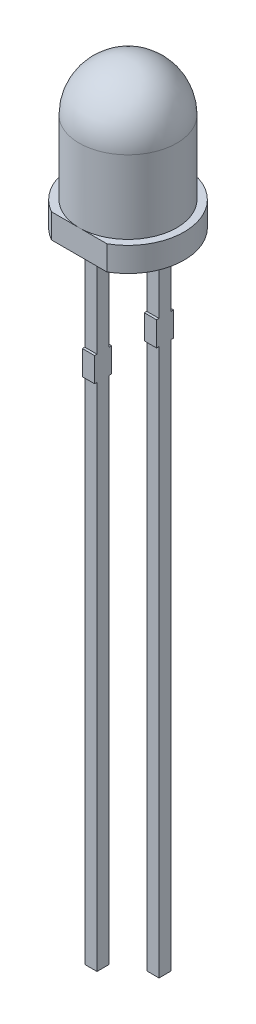
from build123d import *

# Parameters (mm, degrees)
EXTRUDE1_DEPTH     = 1
SKETCH3_W          = 0.5
SKETCH3_H          = 0.5
EXTRUDE2_DEPTH     = 25.5
SKETCH3_3_W        = 0.5
SKETCH3_3_H        = 0.5
EXTRUDE3_DEPTH     = 27
SKETCH4_W          = 0.7
SKETCH4_H          = 1
EXTRUDE4_DEPTH     = 0.5
SKETCH5_W          = 0.026582278
SKETCH5_H          = 0.025316456
CUT_EXTRUDE1_DEPTH = 0.01


with BuildPart() as part:
    # Sketch1 → Revolve1 (revolve)
    with BuildSketch(Plane.XY):
        with BuildLine():
            ThreePointArc((0, 5), (1.414213562, 4.414213562), (2, 3))
            Line((2, 3), (2, 0))
            Line((2, 0), (0, 0))
            Line((0, 0), (0, 5))
        make_face()
    revolve(axis=Axis((0, 0, 0), (0, 1, 0)))

    # Sketch2 → Extrude1 (add)
    with BuildSketch(Plane.XZ.offset(1)):
        with BuildLine():
            ThreePointArc((-1.135781669, 2), (0, -2.3), (1.135781669, 2))
            Line((1.135781669, 2), (-1.135781669, 2))
        make_face()
    extrude(amount=-EXTRUDE1_DEPTH)

    # Sketch3 → Extrude2 (add)
    with BuildSketch(Plane.XZ.offset(1)):
        with Locations((0, 1.27)):
            Rectangle(SKETCH3_W, SKETCH3_H)
    extrude(amount=EXTRUDE2_DEPTH)

    # Sketch3_3 → Extrude3 (add)
    with BuildSketch(Plane.XZ.offset(1)):
        with Locations((0, -1.27)):
            Rectangle(SKETCH3_3_W, SKETCH3_3_H)
    extrude(amount=EXTRUDE3_DEPTH)

    # Sketch4 → Extrude4 (add)
    with BuildSketch(Plane.ZY.offset(0.25)):
        with Locations((-1.27, -5.1)):
            Rectangle(SKETCH4_W, SKETCH4_H)
        with Locations((1.27, -5.1)):
            Rectangle(SKETCH4_W, SKETCH4_H)
    extrude(amount=-EXTRUDE4_DEPTH)

    # Sketch5 → Cut-Extrude1 (cut)
    with BuildSketch(Plane.XZ.offset(1)):
        Polygon((-0.175316456, 0.572151899), (-0.25, 0.595609177), (-0.25, 0.620352057), (-0.199663766, 0.636768196), (-0.25, 0.652294304), (-0.25, 0.678026108), (-0.175316456, 0.701265823), (-0.175316456, 0.676087816), (-0.226799842, 0.663093354), (-0.175316456, 0.646677215), (-0.175316456, 0.625178006), (-0.226799842, 0.608860759), (-0.175316456, 0.596044304), align=None)
        Polygon((-0.175316456, 0.437974684), (-0.25, 0.461431962), (-0.25, 0.486174842), (-0.199663766, 0.502590981), (-0.25, 0.518117089), (-0.25, 0.543848892), (-0.175316456, 0.567088608), (-0.175316456, 0.541910601), (-0.226799842, 0.528916139), (-0.175316456, 0.5125), (-0.175316456, 0.491000791), (-0.226799842, 0.474683544), (-0.175316456, 0.461867089), align=None)
        Polygon((-0.175316456, 0.303797468), (-0.25, 0.327254747), (-0.25, 0.351997627), (-0.199663766, 0.368413766), (-0.25, 0.383939873), (-0.25, 0.409671677), (-0.175316456, 0.432911392), (-0.175316456, 0.407733386), (-0.226799842, 0.394738924), (-0.175316456, 0.378322785), (-0.175316456, 0.356823576), (-0.226799842, 0.340506329), (-0.175316456, 0.327689873), align=None)
        with Locations((-0.236708861, 0.275949367)):
            Rectangle(SKETCH5_W, SKETCH5_H)
        with BuildLine():
            add(Edge.make_bspline(
                [(-0.218829114, 0.159493671), (-0.220051248, 0.159530169), (-0.22245111, 0.15960184), (-0.225958798, 0.160211426), (-0.229283102, 0.161205393), (-0.232447248, 0.162577732), (-0.235416736, 0.164371189), (-0.238219628, 0.16655446), (-0.240824172, 0.169143343), (-0.243260547, 0.172090146), (-0.245442658, 0.175387089), (-0.247348691, 0.178984804), (-0.248943362, 0.18286483), (-0.250282428, 0.187013042), (-0.251270861, 0.191459588), (-0.251994849, 0.196177087), (-0.252468166, 0.201170514), (-0.252510134, 0.204594091), (-0.252531646, 0.206348892)],
                knots=[0, 0, 0, 0, 0.907312236, 1.78165839, 2.635367075, 3.479697475, 4.336364812, 5.205276731, 6.11257575, 7.058770404, 8.040786331, 9.044147278, 10.078219212, 11.153049307, 12.278104542, 13.457648573, 14.696882856, 16, 16, 16, 16], degree=3))
            add(Edge.make_bspline(
                [(-0.252531646, 0.206348892), (-0.252507574, 0.208367148), (-0.252460949, 0.21227633), (-0.25203235, 0.217939855), (-0.251386211, 0.223207892), (-0.250419669, 0.228103607), (-0.249218904, 0.232708206), (-0.247927612, 0.237141474), (-0.246463197, 0.241422786), (-0.245363039, 0.244195876), (-0.244818038, 0.24556962)],
                knots=[0, 0, 0, 0, 1.203215828, 2.33052265, 3.384689099, 4.366106119, 5.303329643, 6.221311756, 7.118865988, 8, 8, 8, 8], degree=3))
            Line((-0.244818038, 0.24556962), (-0.220886076, 0.24556962))
            Line((-0.220886076, 0.24556962), (-0.220886076, 0.242721519))
            add(Edge.make_bspline(
                [(-0.220886076, 0.242721519), (-0.221967531, 0.241356205), (-0.224124092, 0.238633592), (-0.226886697, 0.234200359), (-0.22928886, 0.229552713), (-0.231262862, 0.224707243), (-0.232849186, 0.219810398), (-0.233942713, 0.21493502), (-0.234690062, 0.210169433), (-0.234770569, 0.207010864), (-0.234810127, 0.205458861)],
                knots=[0, 0, 0, 0, 1.030622468, 2.055194264, 3.087043286, 4.125157485, 5.149848264, 6.130935704, 7.081611712, 8, 8, 8, 8], degree=3))
            add(Edge.make_bspline(
                [(-0.234810127, 0.205458861), (-0.234809232, 0.205030082), (-0.234807317, 0.2041121), (-0.234678474, 0.202644063), (-0.234585311, 0.200985464), (-0.234376093, 0.199206598), (-0.23415751, 0.197415781), (-0.23377719, 0.195761121), (-0.233415351, 0.194257482), (-0.233047173, 0.193351), (-0.232871835, 0.192919304)],
                knots=[0, 0, 0, 0, 0.806378557, 1.726393851, 2.771014456, 3.931269413, 5.096090628, 6.161710732, 7.124547685, 8, 8, 8, 8], degree=3))
            add(Edge.make_bspline(
                [(-0.232871835, 0.192919304), (-0.232644012, 0.192439517), (-0.23219629, 0.191496634), (-0.231378683, 0.190201714), (-0.230507381, 0.189019042), (-0.229541962, 0.187957582), (-0.228364053, 0.187107314), (-0.226963197, 0.186479113), (-0.225312897, 0.186136019), (-0.224137886, 0.186096725), (-0.223516614, 0.186075949)],
                knots=[0, 0, 0, 0, 1.024407818, 2.013179384, 2.949802342, 3.859052226, 4.77034807, 5.732977883, 6.801339628, 8, 8, 8, 8], degree=3))
            add(Edge.make_bspline(
                [(-0.223516614, 0.186075949), (-0.222970718, 0.186107391), (-0.221897325, 0.186169215), (-0.220369329, 0.186751006), (-0.218947452, 0.187633905), (-0.217686737, 0.188920927), (-0.216529299, 0.190515003), (-0.215559002, 0.19247074), (-0.214678928, 0.194723719), (-0.214261659, 0.196368178), (-0.214042722, 0.197231013)],
                knots=[0, 0, 0, 0, 0.825212765, 1.622611382, 2.449701629, 3.348069183, 4.336544339, 5.428209675, 6.6506027, 8, 8, 8, 8], degree=3))
            add(Edge.make_bspline(
                [(-0.214042722, 0.197231013), (-0.213594981, 0.19919974), (-0.212677791, 0.203232648), (-0.211530684, 0.209380757), (-0.210264611, 0.215510984), (-0.20905507, 0.219469696), (-0.20846519, 0.221400316)],
                knots=[0, 0, 0, 0, 0.976104583, 1.999535498, 3.024395274, 4, 4, 4, 4], degree=3))
            add(Edge.make_bspline(
                [(-0.20846519, 0.221400316), (-0.208112197, 0.222438832), (-0.207425064, 0.224460401), (-0.206263439, 0.227351945), (-0.204993487, 0.230013057), (-0.203638356, 0.232453168), (-0.202164358, 0.23465249), (-0.200630968, 0.236647679), (-0.198977131, 0.238391205), (-0.197245211, 0.239938889), (-0.195393209, 0.241262203), (-0.193449072, 0.242416954), (-0.191388607, 0.243392589), (-0.189227318, 0.244201473), (-0.18694845, 0.244818545), (-0.184571576, 0.245239801), (-0.182088216, 0.24553819), (-0.180393863, 0.245559001), (-0.179529272, 0.24556962)],
                knots=[0, 0, 0, 0, 1.287286806, 2.505824366, 3.654938963, 4.74627059, 5.778586806, 6.75996495, 7.696030012, 8.595059759, 9.482019644, 10.363222407, 11.245851011, 12.154256429, 13.068444161, 14.012503255, 14.985824751, 16, 16, 16, 16], degree=3))
            add(Edge.make_bspline(
                [(-0.179529272, 0.24556962), (-0.178373127, 0.245532318), (-0.176097855, 0.245458909), (-0.172768811, 0.24485748), (-0.169620074, 0.24383089), (-0.166616611, 0.242444827), (-0.163803525, 0.240616199), (-0.161124978, 0.238431404), (-0.158653386, 0.235807357), (-0.156353053, 0.232830235), (-0.154273654, 0.229542851), (-0.152443098, 0.226003867), (-0.150906446, 0.222234578), (-0.149632552, 0.218249032), (-0.148677881, 0.214030563), (-0.14795895, 0.20959333), (-0.147545768, 0.204919541), (-0.147494518, 0.20172812), (-0.147468354, 0.200098892)],
                knots=[0, 0, 0, 0, 0.894990994, 1.761326291, 2.609044902, 3.454222546, 4.315366365, 5.200560057, 6.125081389, 7.100429509, 8.110379559, 9.133447974, 10.182136699, 11.259192205, 12.370181258, 13.528580438, 14.738335141, 16, 16, 16, 16], degree=3))
            add(Edge.make_bspline(
                [(-0.147468354, 0.200098892), (-0.147490546, 0.198430205), (-0.147534891, 0.19509566), (-0.147912869, 0.190114218), (-0.148468097, 0.185153716), (-0.149309803, 0.180289886), (-0.15028622, 0.175599331), (-0.151382015, 0.171186095), (-0.15261998, 0.167106634), (-0.153574325, 0.16453297), (-0.15403481, 0.163291139)],
                knots=[0, 0, 0, 0, 1.065403572, 2.129000689, 3.188532477, 4.251604565, 5.279552602, 6.247508681, 7.154397237, 8, 8, 8, 8], degree=3))
            Line((-0.15403481, 0.163291139), (-0.176582278, 0.163291139))
            Line((-0.176582278, 0.163291139), (-0.176582278, 0.166119462))
            add(Edge.make_bspline(
                [(-0.176582278, 0.166119462), (-0.175781932, 0.167192367), (-0.174145202, 0.169386485), (-0.17206153, 0.173046122), (-0.170103664, 0.177004358), (-0.168419505, 0.181283188), (-0.166960024, 0.185742216), (-0.165940858, 0.190325174), (-0.165299048, 0.194951338), (-0.165226273, 0.198053049), (-0.165189873, 0.19960443)],
                knots=[0, 0, 0, 0, 0.892283326, 1.824742884, 2.804416662, 3.836872171, 4.8899239, 5.931447339, 6.965372909, 8, 8, 8, 8], degree=3))
            add(Edge.make_bspline(
                [(-0.165189873, 0.19960443), (-0.165211326, 0.200700098), (-0.165254228, 0.202891315), (-0.165644912, 0.206159523), (-0.166275806, 0.209401584), (-0.167095088, 0.211442107), (-0.167503956, 0.212460443)],
                knots=[0, 0, 0, 0, 0.999146175, 1.998183711, 3.000980573, 4, 4, 4, 4], degree=3))
            add(Edge.make_bspline(
                [(-0.167503956, 0.212460443), (-0.167705423, 0.212893946), (-0.168108222, 0.213760664), (-0.168880786, 0.214967308), (-0.169809597, 0.216071977), (-0.170861589, 0.217064055), (-0.172017962, 0.217932452), (-0.173292788, 0.218547803), (-0.174655703, 0.218923676), (-0.175590934, 0.218965835), (-0.176068038, 0.218987342)],
                knots=[0, 0, 0, 0, 1.00524851, 2.009826503, 3.004679593, 4.035271301, 5.048246368, 6.034938417, 6.997532266, 8, 8, 8, 8], degree=3))
            add(Edge.make_bspline(
                [(-0.176068038, 0.218987342), (-0.176706203, 0.218952904), (-0.177925679, 0.218887095), (-0.179641475, 0.218280511), (-0.181119909, 0.217295678), (-0.182114829, 0.216135073), (-0.182812267, 0.215017943), (-0.183322777, 0.213982284), (-0.183806136, 0.212773057), (-0.184303605, 0.211401809), (-0.184794792, 0.209865482), (-0.185270339, 0.208156925), (-0.185719635, 0.206274208), (-0.186005825, 0.204958333), (-0.186155063, 0.204272152)],
                knots=[0, 0, 0, 0, 1.173816843, 2.243057204, 3.312297565, 4.415174738, 5.03266065, 5.73970059, 6.541434878, 7.433956553, 8.430083051, 9.515931566, 10.70464786, 12, 12, 12, 12], degree=3))
            add(Edge.make_bspline(
                [(-0.186155063, 0.204272152), (-0.186531125, 0.202439363), (-0.187270003, 0.198838337), (-0.188373491, 0.193437153), (-0.18964846, 0.18793438), (-0.190797263, 0.184269053), (-0.191396361, 0.182357595)],
                knots=[0, 0, 0, 0, 0.995744513, 1.956417928, 2.934277412, 4, 4, 4, 4], degree=3))
            add(Edge.make_bspline(
                [(-0.191396361, 0.182357595), (-0.191715605, 0.181411041), (-0.192340097, 0.179559428), (-0.19342638, 0.176918797), (-0.194600363, 0.174471738), (-0.195841894, 0.172204706), (-0.19718586, 0.170130736), (-0.198608507, 0.168236053), (-0.200135416, 0.166552235), (-0.201748644, 0.16505467), (-0.203458744, 0.16373551), (-0.205297817, 0.162603212), (-0.207246619, 0.161630984), (-0.209332819, 0.160861379), (-0.211527406, 0.160243358), (-0.213858774, 0.159820261), (-0.21630315, 0.159526278), (-0.217977728, 0.159504661), (-0.218829114, 0.159493671)],
                knots=[0, 0, 0, 0, 1.237467875, 2.420686895, 3.535046182, 4.599015201, 5.620884487, 6.594603852, 7.531477383, 8.433220087, 9.318759595, 10.202828513, 11.105163009, 12.01247538, 12.953896178, 13.926381251, 14.945733412, 16, 16, 16, 16], degree=3))
        make_face()
        with BuildLine():
            Line((-0.25, 0.067088608), (-0.25, 0.091139241))
            Line((-0.25, 0.091139241), (-0.242167722, 0.091139241))
            add(Edge.make_bspline(
                [(-0.242167722, 0.091139241), (-0.24297628, 0.092232549), (-0.244535168, 0.094340433), (-0.246615386, 0.097513458), (-0.248390652, 0.100539548), (-0.249949873, 0.103453039), (-0.251125258, 0.106475242), (-0.251953324, 0.109706756), (-0.252453097, 0.113209581), (-0.252504881, 0.115636475), (-0.252531646, 0.116890823)],
                knots=[0, 0, 0, 0, 1.150872466, 2.218865267, 3.209461834, 4.120482262, 5.012764827, 5.946708227, 6.938749913, 8, 8, 8, 8], degree=3))
            add(Edge.make_bspline(
                [(-0.252531646, 0.116890823), (-0.252508927, 0.117907175), (-0.252464686, 0.119886305), (-0.252119808, 0.122763545), (-0.251582157, 0.125471173), (-0.250774566, 0.127986213), (-0.249808763, 0.130350202), (-0.248528805, 0.132487752), (-0.247098631, 0.134491354), (-0.245391585, 0.136273026), (-0.243493852, 0.137888648), (-0.241361392, 0.139271198), (-0.239028466, 0.140448909), (-0.236476612, 0.141390006), (-0.233718309, 0.142145096), (-0.230739061, 0.142669028), (-0.227551934, 0.142989621), (-0.225356803, 0.14302156), (-0.224228639, 0.143037975)],
                knots=[0, 0, 0, 0, 1.109008058, 2.159558935, 3.158726032, 4.116861086, 5.039058877, 5.938775559, 6.82970133, 7.720510853, 8.624361809, 9.544451588, 10.487360536, 11.471068125, 12.508000841, 13.604731202, 14.768976642, 16, 16, 16, 16], degree=3))
            Line((-0.224228639, 0.143037975), (-0.175316456, 0.143037975))
            Line((-0.175316456, 0.143037975), (-0.175316456, 0.118987342))
            Line((-0.175316456, 0.118987342), (-0.21289557, 0.118987342))
            add(Edge.make_bspline(
                [(-0.21289557, 0.118987342), (-0.213812041, 0.118985706), (-0.215566256, 0.118982576), (-0.218072063, 0.118900237), (-0.220340235, 0.118779336), (-0.222382264, 0.118640631), (-0.224229015, 0.118387615), (-0.225895176, 0.118009906), (-0.227414778, 0.11753908), (-0.228321479, 0.117074761), (-0.228757911, 0.116851266)],
                knots=[0, 0, 0, 0, 1.361401701, 2.605856924, 3.723918663, 4.735739235, 5.645738665, 6.489217889, 7.27279937, 8, 8, 8, 8], degree=3))
            add(Edge.make_bspline(
                [(-0.228757911, 0.116851266), (-0.229156626, 0.116621259), (-0.229940466, 0.116169086), (-0.230946644, 0.115248796), (-0.231790911, 0.114170053), (-0.23244694, 0.112892449), (-0.232945889, 0.111405901), (-0.233286125, 0.109677971), (-0.233501627, 0.107692609), (-0.233529535, 0.106283591), (-0.233544304, 0.105537975)],
                knots=[0, 0, 0, 0, 0.849138082, 1.669332372, 2.503455908, 3.370611167, 4.311442699, 5.394692208, 6.621337967, 8, 8, 8, 8], degree=3))
            add(Edge.make_bspline(
                [(-0.233544304, 0.105537975), (-0.233526947, 0.104996691), (-0.233491259, 0.103883773), (-0.233258814, 0.102172461), (-0.232902139, 0.100375884), (-0.232242283, 0.097861301), (-0.231056104, 0.094694674), (-0.229701697, 0.092335372), (-0.229015032, 0.091139241)],
                knots=[0, 0, 0, 0, 0.638127216, 1.312033637, 2.033062677, 2.79661882, 4.375931797, 6, 6, 6, 6], degree=3))
            Line((-0.229015032, 0.091139241), (-0.175316456, 0.091139241))
            Line((-0.175316456, 0.091139241), (-0.175316456, 0.067088608))
            Line((-0.175316456, 0.067088608), (-0.25, 0.067088608))
        make_face()
        with BuildLine():
            Line((-0.25, -0.030379747), (-0.25, -0.006329114))
            Line((-0.25, -0.006329114), (-0.212420886, -0.006329114))
            add(Edge.make_bspline(
                [(-0.212420886, -0.006329114), (-0.210890843, -0.0063046), (-0.207839818, -0.006255716), (-0.204077407, -0.005973592), (-0.201235083, -0.00559507), (-0.199397202, -0.005225415), (-0.197849063, -0.004793715), (-0.196963303, -0.004381435), (-0.196558544, -0.004193038)],
                knots=[0, 0, 0, 0, 1.709124929, 3.408128882, 4.211124727, 4.91016634, 5.501986363, 6, 6, 6, 6], degree=3))
            add(Edge.make_bspline(
                [(-0.196558544, -0.004193038), (-0.196160491, -0.003948575), (-0.195380051, -0.003469272), (-0.194367038, -0.002531948), (-0.193538197, -0.001438061), (-0.192856647, -0.000167292), (-0.192386066, 0.001323905), (-0.191992836, 0.003040645), (-0.191825927, 0.005027263), (-0.191790767, 0.006434533), (-0.191772152, 0.007179589)],
                knots=[0, 0, 0, 0, 0.86006424, 1.686277094, 2.52783008, 3.38194165, 4.331801563, 5.402842185, 6.624978739, 8, 8, 8, 8], degree=3))
            add(Edge.make_bspline(
                [(-0.191772152, 0.007179589), (-0.191828889, 0.00831141), (-0.191944743, 0.010622505), (-0.19265625, 0.013484698), (-0.193475209, 0.015815302), (-0.19423404, 0.017667827), (-0.195205482, 0.019576457), (-0.195927304, 0.020855869), (-0.196301424, 0.021518987)],
                knots=[0, 0, 0, 0, 1.338371478, 2.732853438, 3.468019217, 4.261884641, 5.099136535, 6, 6, 6, 6], degree=3))
            Line((-0.196301424, 0.021518987), (-0.25, 0.021518987))
            Line((-0.25, 0.021518987), (-0.25, 0.04556962))
            Line((-0.25, 0.04556962), (-0.175316456, 0.04556962))
            Line((-0.175316456, 0.04556962), (-0.175316456, 0.021518987))
            Line((-0.175316456, 0.021518987), (-0.183148734, 0.021518987))
            add(Edge.make_bspline(
                [(-0.183148734, 0.021518987), (-0.182342583, 0.020461581), (-0.18077336, 0.018403276), (-0.17873294, 0.015224038), (-0.176934171, 0.01214014), (-0.175421354, 0.009087131), (-0.174214579, 0.005972176), (-0.17340359, 0.002709417), (-0.172859787, -0.000706989), (-0.172810094, -0.003043704), (-0.17278481, -0.004232595)],
                knots=[0, 0, 0, 0, 1.126119141, 2.192057864, 3.198061997, 4.149848529, 5.076251285, 6.021887753, 6.99356175, 8, 8, 8, 8], degree=3))
            add(Edge.make_bspline(
                [(-0.17278481, -0.004232595), (-0.172810199, -0.005228866), (-0.172859763, -0.007173765), (-0.173169473, -0.010008526), (-0.173720137, -0.012679947), (-0.174517966, -0.015172221), (-0.175503578, -0.017514841), (-0.176735093, -0.019676785), (-0.178193516, -0.021668856), (-0.179854519, -0.023497257), (-0.181744245, -0.025128075), (-0.18386151, -0.026545111), (-0.186204606, -0.027725092), (-0.188764915, -0.028695805), (-0.191530024, -0.029470228), (-0.19452599, -0.029985359), (-0.197730169, -0.030339143), (-0.199946212, -0.030365941), (-0.201087816, -0.030379747)],
                knots=[0, 0, 0, 0, 1.08848837, 2.124922927, 3.110950502, 4.063144162, 4.979605775, 5.882838355, 6.774625441, 7.671951181, 8.57587277, 9.494821853, 10.448322275, 11.435533005, 12.482327682, 13.580118324, 14.753386918, 16, 16, 16, 16], degree=3))
            Line((-0.201087816, -0.030379747), (-0.25, -0.030379747))
        make_face()
        Polygon((-0.25, -0.125316456), (-0.25, -0.053164557), (-0.15, -0.053164557), (-0.15, -0.078481013), (-0.231012658, -0.078481013), (-0.231012658, -0.125316456), align=None)
        Polygon((-0.25, -0.212658228), (-0.25, -0.140506329), (-0.15, -0.140506329), (-0.15, -0.212658228), (-0.168987342, -0.212658228), (-0.168987342, -0.165822785), (-0.186708861, -0.165822785), (-0.186708861, -0.208860759), (-0.205696203, -0.208860759), (-0.205696203, -0.165822785), (-0.231012658, -0.165822785), (-0.231012658, -0.212658228), align=None)
        with BuildLine():
            add(Edge.make_bspline(
                [(-0.200098892, -0.329113924), (-0.201246581, -0.329094609), (-0.203519467, -0.329056357), (-0.206884274, -0.328761165), (-0.210149949, -0.32823514), (-0.213334198, -0.327555959), (-0.216413126, -0.326633453), (-0.219420703, -0.325551739), (-0.222326196, -0.324242093), (-0.225127631, -0.322737241), (-0.227799734, -0.321087768), (-0.230319942, -0.319313019), (-0.23270316, -0.31746724), (-0.234898054, -0.315477927), (-0.236940074, -0.313398746), (-0.238830888, -0.311223217), (-0.240534319, -0.308918153), (-0.241557203, -0.30731099), (-0.242068829, -0.30650712)],
                knots=[0, 0, 0, 0, 1.105570398, 2.18947457, 3.250358341, 4.290584537, 5.323553275, 6.344225964, 7.367641686, 8.3905646, 9.405808457, 10.390761353, 11.358902336, 12.307789878, 13.241960776, 14.165076779, 15.082208636, 16, 16, 16, 16], degree=3))
            add(Edge.make_bspline(
                [(-0.242068829, -0.30650712), (-0.242780968, -0.305267892), (-0.244208881, -0.302783112), (-0.245877472, -0.298799278), (-0.247281588, -0.294673795), (-0.248336012, -0.290323409), (-0.249063056, -0.285676399), (-0.249623862, -0.28067499), (-0.249925622, -0.275267401), (-0.249974642, -0.271532506), (-0.25, -0.269600475)],
                knots=[0, 0, 0, 0, 0.896288622, 1.797150563, 2.705281913, 3.629615989, 4.602417572, 5.655716007, 6.787320449, 8, 8, 8, 8], degree=3))
            Line((-0.25, -0.269600475), (-0.25, -0.234177215))
            Line((-0.25, -0.234177215), (-0.15, -0.234177215))
            Line((-0.15, -0.234177215), (-0.15, -0.270609177))
            add(Edge.make_bspline(
                [(-0.15, -0.270609177), (-0.150016611, -0.272587909), (-0.150048652, -0.276404637), (-0.150466242, -0.281921476), (-0.151063066, -0.287026684), (-0.151987937, -0.291712032), (-0.153103282, -0.296012037), (-0.154462411, -0.299937513), (-0.155961118, -0.303549287), (-0.157234811, -0.305728129), (-0.157852057, -0.306784019)],
                knots=[0, 0, 0, 0, 1.267175336, 2.444223962, 3.542125549, 4.557526608, 5.500936977, 6.385043188, 7.217374394, 8, 8, 8, 8], degree=3))
            add(Edge.make_bspline(
                [(-0.157852057, -0.306784019), (-0.158388598, -0.307634972), (-0.159455511, -0.309327097), (-0.161237363, -0.311728312), (-0.16319344, -0.313957739), (-0.165245259, -0.316086242), (-0.167448146, -0.318066059), (-0.169786853, -0.319909259), (-0.172264947, -0.321613076), (-0.174874416, -0.323171039), (-0.177604468, -0.324591854), (-0.180477527, -0.32578116), (-0.183456057, -0.326830509), (-0.186565019, -0.327636046), (-0.189772856, -0.32833396), (-0.1931142, -0.328768694), (-0.196566688, -0.329055305), (-0.198911578, -0.32909422), (-0.200098892, -0.329113924)],
                knots=[0, 0, 0, 0, 0.964065863, 1.917049184, 2.86229036, 3.805247319, 4.749389377, 5.698846072, 6.657678277, 7.629829384, 8.610569287, 9.604676042, 10.607940105, 11.6349849, 12.681042988, 13.752616828, 14.862056989, 16, 16, 16, 16], degree=3))
        make_face()
        with BuildLine():
            add(Edge.make_bspline(
                [(-0.199940665, -0.302531646), (-0.199135905, -0.302521405), (-0.197557321, -0.302501317), (-0.195241806, -0.30230975), (-0.193012156, -0.302050694), (-0.190877464, -0.30161964), (-0.188817893, -0.301119993), (-0.186860399, -0.300477843), (-0.184980826, -0.299753447), (-0.183203337, -0.298871809), (-0.181494955, -0.297898172), (-0.17990944, -0.296750679), (-0.178396553, -0.295502341), (-0.176968569, -0.294124054), (-0.175662673, -0.292581114), (-0.174432597, -0.290921012), (-0.173304271, -0.289120654), (-0.172644221, -0.287847665), (-0.172310127, -0.287203323)],
                knots=[0, 0, 0, 0, 1.152093354, 2.259898929, 3.325467225, 4.364140538, 5.376172865, 6.358396836, 7.312077728, 8.257828931, 9.196960457, 10.124297759, 11.056236784, 12.004246951, 12.961658638, 13.947279359, 14.960983522, 16, 16, 16, 16], degree=3))
            add(Edge.make_bspline(
                [(-0.172310127, -0.287203323), (-0.172003415, -0.286528425), (-0.17139549, -0.285190731), (-0.170664298, -0.283119908), (-0.170091462, -0.281030524), (-0.169660604, -0.278828925), (-0.169338673, -0.276359165), (-0.169141415, -0.273433583), (-0.168999245, -0.269977674), (-0.168991494, -0.267490959), (-0.168987342, -0.266159019)],
                knots=[0, 0, 0, 0, 0.826967603, 1.639107464, 2.447640171, 3.242670507, 4.14065217, 5.225198036, 6.513753944, 8, 8, 8, 8], degree=3))
            Line((-0.168987342, -0.266159019), (-0.168987342, -0.259493671))
            Line((-0.168987342, -0.259493671), (-0.231012658, -0.259493671))
            Line((-0.231012658, -0.259493671), (-0.231012658, -0.266159019))
            add(Edge.make_bspline(
                [(-0.231012658, -0.266159019), (-0.231007909, -0.266917226), (-0.230998739, -0.268380991), (-0.230955677, -0.270497235), (-0.230908789, -0.272463031), (-0.230792327, -0.274267902), (-0.230719681, -0.275926587), (-0.230541302, -0.277413368), (-0.230399122, -0.278755857), (-0.230131399, -0.280323454), (-0.229715216, -0.28217662), (-0.229037037, -0.28433788), (-0.228186642, -0.286478414), (-0.227501675, -0.287866987), (-0.227155854, -0.288568038)],
                knots=[0, 0, 0, 0, 1.186793418, 2.291178421, 3.313283093, 4.264083014, 5.122158624, 5.910777728, 6.607099052, 7.234812932, 8.398911528, 9.577194775, 10.776795607, 12, 12, 12, 12], degree=3))
            add(Edge.make_bspline(
                [(-0.227155854, -0.288568038), (-0.226814338, -0.289153154), (-0.226140824, -0.29030708), (-0.22500675, -0.291930584), (-0.223799025, -0.293438302), (-0.222510574, -0.294834314), (-0.221122333, -0.296097614), (-0.219655791, -0.297249633), (-0.218107813, -0.298280082), (-0.215914295, -0.299515471), (-0.212883358, -0.300738716), (-0.208915972, -0.301778259), (-0.204556209, -0.30241513), (-0.201518591, -0.302491812), (-0.199940665, -0.302531646)],
                knots=[0, 0, 0, 0, 0.755160452, 1.489275589, 2.205657296, 2.907868421, 3.605098304, 4.296256403, 4.985378686, 5.676536785, 7.100390329, 8.614249252, 10.241231541, 12, 12, 12, 12], degree=3))
        make_face(mode=Mode.SUBTRACT)
        with Locations((-0.236708861, -0.360759494)):
            Rectangle(SKETCH5_W, SKETCH5_H)
        with BuildLine():
            add(Edge.make_bspline(
                [(-0.252531646, -0.435403481), (-0.252509834, -0.433813368), (-0.252467023, -0.430692232), (-0.251990106, -0.42612089), (-0.25127241, -0.421755717), (-0.250251504, -0.417609409), (-0.248904008, -0.413695618), (-0.247251072, -0.41003198), (-0.245265888, -0.406625123), (-0.243686679, -0.404566476), (-0.242899525, -0.403540348)],
                knots=[0, 0, 0, 0, 1.123670284, 2.205584497, 3.245308791, 4.249063313, 5.220352711, 6.167273909, 7.086481357, 8, 8, 8, 8], degree=3))
            add(Edge.make_bspline(
                [(-0.242899525, -0.403540348), (-0.242044751, -0.402588601), (-0.240338508, -0.400688786), (-0.237367081, -0.398222853), (-0.234084037, -0.396099767), (-0.230481815, -0.394314215), (-0.226565086, -0.392883291), (-0.222320424, -0.391860157), (-0.217759643, -0.391240912), (-0.21461171, -0.391173746), (-0.212994462, -0.391139241)],
                knots=[0, 0, 0, 0, 0.916457077, 1.82937027, 2.759194969, 3.714948755, 4.706655623, 5.743329475, 6.840637961, 8, 8, 8, 8], degree=3))
            add(Edge.make_bspline(
                [(-0.212994462, -0.391139241), (-0.211291235, -0.391178001), (-0.207990155, -0.391253124), (-0.203217967, -0.391916883), (-0.198800287, -0.392986496), (-0.194748378, -0.394524054), (-0.191055187, -0.396454496), (-0.187683352, -0.398718989), (-0.184640428, -0.401339514), (-0.182894988, -0.403346653), (-0.182021361, -0.404351266)],
                knots=[0, 0, 0, 0, 1.171797512, 2.271099083, 3.308930235, 4.294129479, 5.24602549, 6.17106565, 7.084581485, 8, 8, 8, 8], degree=3))
            add(Edge.make_bspline(
                [(-0.182021361, -0.404351266), (-0.181252774, -0.405377136), (-0.179706318, -0.407441268), (-0.177805619, -0.410844773), (-0.176210833, -0.414467988), (-0.174963188, -0.418297559), (-0.174009283, -0.422270367), (-0.173285439, -0.426330027), (-0.172864881, -0.43047628), (-0.172811629, -0.43326648), (-0.17278481, -0.434671677)],
                knots=[0, 0, 0, 0, 0.952130878, 1.915761808, 2.890227217, 3.891541892, 4.905612075, 5.925811839, 6.955400088, 8, 8, 8, 8], degree=3))
            add(Edge.make_bspline(
                [(-0.17278481, -0.434671677), (-0.172801812, -0.435918396), (-0.172835245, -0.438369867), (-0.173157354, -0.441970914), (-0.173690473, -0.445425455), (-0.174429076, -0.448730387), (-0.175320679, -0.451904334), (-0.17635982, -0.454954511), (-0.177493088, -0.457914321), (-0.178377623, -0.45981489), (-0.178817247, -0.460759494)],
                knots=[0, 0, 0, 0, 1.107648782, 2.178012834, 3.209595929, 4.211695017, 5.185427128, 6.137685403, 7.07440854, 8, 8, 8, 8], degree=3))
            Line((-0.178817247, -0.460759494), (-0.199367089, -0.460759494))
            Line((-0.199367089, -0.460759494), (-0.199367089, -0.45741693))
            add(Edge.make_bspline(
                [(-0.199367089, -0.45741693), (-0.198949869, -0.456917386), (-0.198048154, -0.45583775), (-0.196627402, -0.454051335), (-0.195097809, -0.451902393), (-0.194205863, -0.450248857), (-0.193730222, -0.449367089)],
                knots=[0, 0, 0, 0, 0.792826818, 1.713491785, 2.780691913, 4, 4, 4, 4], degree=3))
            add(Edge.make_bspline(
                [(-0.193730222, -0.449367089), (-0.193288264, -0.448439154), (-0.192382404, -0.446537209), (-0.19154957, -0.443981204), (-0.190981844, -0.441789202), (-0.190725422, -0.439971666), (-0.190535861, -0.438038046), (-0.190516354, -0.436702803), (-0.190506329, -0.436016614)],
                knots=[0, 0, 0, 0, 1.332524827, 2.731214173, 3.480270227, 4.267952375, 5.109889624, 6, 6, 6, 6], degree=3))
            add(Edge.make_bspline(
                [(-0.190506329, -0.436016614), (-0.190525879, -0.435251058), (-0.190563765, -0.433767448), (-0.190840821, -0.431605939), (-0.191319079, -0.429587528), (-0.191959179, -0.427684306), (-0.192846792, -0.425946243), (-0.193880429, -0.424319403), (-0.195106231, -0.422827143), (-0.196547173, -0.421507882), (-0.198127102, -0.420315156), (-0.199861217, -0.419295954), (-0.201707816, -0.418383498), (-0.203712265, -0.41768856), (-0.205841041, -0.417128822), (-0.208104161, -0.416739892), (-0.210503671, -0.416497934), (-0.212149979, -0.416470016), (-0.212994462, -0.416455696)],
                knots=[0, 0, 0, 0, 1.087302107, 2.107140881, 3.088415001, 4.030197574, 4.951552271, 5.852940509, 6.764198256, 7.685219758, 8.621679636, 9.570836121, 10.538340132, 11.542450476, 12.578202196, 13.66207107, 14.800746211, 16, 16, 16, 16], degree=3))
            add(Edge.make_bspline(
                [(-0.212994462, -0.416455696), (-0.213858618, -0.416470471), (-0.215537631, -0.416499177), (-0.217979242, -0.416732691), (-0.220260673, -0.417148582), (-0.222385993, -0.41771983), (-0.224352011, -0.418444178), (-0.226149408, -0.419349295), (-0.227806215, -0.420385652), (-0.229268827, -0.42163021), (-0.230585149, -0.422994093), (-0.231721283, -0.424508985), (-0.232669428, -0.426168224), (-0.233473891, -0.427950405), (-0.234052289, -0.429883445), (-0.234488981, -0.431939982), (-0.234777538, -0.434129537), (-0.234799101, -0.435639891), (-0.234810127, -0.436412184)],
                knots=[0, 0, 0, 0, 1.230336593, 2.390482092, 3.487897344, 4.52859895, 5.520747884, 6.465347575, 7.38981449, 8.296085817, 9.192433006, 10.084246191, 10.984321635, 11.908883871, 12.862027947, 13.850751296, 14.901019963, 16, 16, 16, 16], degree=3))
            add(Edge.make_bspline(
                [(-0.234810127, -0.436412184), (-0.234801999, -0.437138038), (-0.234786155, -0.438553063), (-0.234568078, -0.44061781), (-0.234292195, -0.442578718), (-0.233852787, -0.444414258), (-0.233310412, -0.446109524), (-0.232743906, -0.447669947), (-0.232139122, -0.449082395), (-0.231671567, -0.449943749), (-0.231447785, -0.450356013)],
                knots=[0, 0, 0, 0, 1.200823684, 2.340960236, 3.433630075, 4.476504061, 5.46014544, 6.378484521, 7.223905657, 8, 8, 8, 8], degree=3))
            add(Edge.make_bspline(
                [(-0.231447785, -0.450356013), (-0.23101789, -0.451056218), (-0.230186248, -0.452410785), (-0.228784682, -0.454249513), (-0.227370422, -0.455894382), (-0.226414205, -0.456918894), (-0.225949367, -0.45741693)],
                knots=[0, 0, 0, 0, 1.098601379, 2.125273733, 3.088655601, 4, 4, 4, 4], degree=3))
            Line((-0.225949367, -0.45741693), (-0.225949367, -0.460759494))
            Line((-0.225949367, -0.460759494), (-0.246657437, -0.460759494))
            add(Edge.make_bspline(
                [(-0.246657437, -0.460759494), (-0.247094931, -0.459814104), (-0.247970024, -0.457923097), (-0.249123896, -0.455008518), (-0.250092057, -0.452020545), (-0.250995137, -0.448972172), (-0.251683499, -0.445800089), (-0.252176622, -0.442477058), (-0.252477534, -0.43899556), (-0.252513362, -0.436617171), (-0.252531646, -0.435403481)],
                knots=[0, 0, 0, 0, 0.952012952, 1.904254716, 2.862729541, 3.822037426, 4.808956931, 5.82647221, 6.890850784, 8, 8, 8, 8], degree=3))
        make_face()
        with BuildLine():
            add(Edge.make_bspline(
                [(-0.212697785, -0.553164557), (-0.214202691, -0.553139862), (-0.217136157, -0.553091723), (-0.221407948, -0.552552407), (-0.225443946, -0.551739627), (-0.229231154, -0.550567096), (-0.232788429, -0.549086703), (-0.236078221, -0.547235764), (-0.239131451, -0.545064759), (-0.241921336, -0.542573722), (-0.244419846, -0.53977252), (-0.246615099, -0.536698338), (-0.248428541, -0.533324511), (-0.249940631, -0.5297102), (-0.251109866, -0.525825548), (-0.251922584, -0.521671329), (-0.252458054, -0.517254195), (-0.252506706, -0.514215776), (-0.252531646, -0.512658228)],
                knots=[0, 0, 0, 0, 1.120167703, 2.183507516, 3.201345984, 4.182878364, 5.131270247, 6.065524964, 6.98789854, 7.91635504, 8.84481154, 9.778033504, 10.722808862, 11.691211189, 12.691525459, 13.738229926, 14.840575679, 16, 16, 16, 16], degree=3))
            add(Edge.make_bspline(
                [(-0.252531646, -0.512658228), (-0.252506624, -0.511100707), (-0.252457811, -0.508062341), (-0.25192348, -0.503644832), (-0.251105529, -0.499485737), (-0.249949428, -0.49559643), (-0.248422879, -0.491987684), (-0.246615831, -0.488617817), (-0.244419638, -0.485544052), (-0.241921446, -0.482742566), (-0.239131219, -0.480252248), (-0.236079037, -0.478078657), (-0.232783083, -0.476236243), (-0.229240037, -0.474718389), (-0.225439199, -0.473585065), (-0.221408758, -0.472761602), (-0.217135938, -0.472225394), (-0.214202617, -0.472176819), (-0.212697785, -0.472151899)],
                knots=[0, 0, 0, 0, 1.15937715, 2.261678054, 3.308339936, 4.313313916, 5.277148057, 6.221884977, 7.155068972, 8.083487698, 9.011906424, 9.934242473, 10.868459181, 11.818729666, 12.798784262, 13.81658132, 14.879877871, 16, 16, 16, 16], degree=3))
            add(Edge.make_bspline(
                [(-0.212697785, -0.472151899), (-0.211186361, -0.472177022), (-0.208233351, -0.472226107), (-0.203934478, -0.472761477), (-0.199873828, -0.473579494), (-0.196065514, -0.474739526), (-0.192513914, -0.476255799), (-0.18921181, -0.478096824), (-0.186165235, -0.480293292), (-0.183375483, -0.48280279), (-0.180879102, -0.485614584), (-0.178706197, -0.488708516), (-0.176869539, -0.492060435), (-0.175347706, -0.495667634), (-0.174213141, -0.49955419), (-0.173395562, -0.503691132), (-0.17285749, -0.508088526), (-0.172809478, -0.511107264), (-0.17278481, -0.512658228)],
                knots=[0, 0, 0, 0, 1.124034801, 2.196132384, 3.217834281, 4.203147447, 5.152578239, 6.085969439, 7.010345409, 7.941219594, 8.872481455, 9.802010446, 10.748267785, 11.711250247, 12.709230373, 13.754967386, 14.846549946, 16, 16, 16, 16], degree=3))
            add(Edge.make_bspline(
                [(-0.17278481, -0.512658228), (-0.172809532, -0.514228966), (-0.172857665, -0.51728713), (-0.173393868, -0.521730542), (-0.174206873, -0.525904381), (-0.175373269, -0.529803006), (-0.176884682, -0.533428756), (-0.17871934, -0.536788831), (-0.180921398, -0.539860139), (-0.183428554, -0.542647393), (-0.186233956, -0.545127634), (-0.189283579, -0.54729655), (-0.192603295, -0.549103768), (-0.196158163, -0.550585538), (-0.199951933, -0.551757711), (-0.203986038, -0.552578696), (-0.208261035, -0.553084687), (-0.211193165, -0.553137471), (-0.212697785, -0.553164557)],
                knots=[0, 0, 0, 0, 1.167358552, 2.272800965, 3.322628764, 4.326027541, 5.29287265, 6.238482395, 7.166210353, 8.096447471, 9.020151799, 9.945039072, 10.873038967, 11.824425184, 12.804379233, 13.820580988, 14.881633558, 16, 16, 16, 16], degree=3))
        make_face()
        with BuildLine():
            add(Edge.make_bspline(
                [(-0.231190665, -0.523457278), (-0.230690658, -0.523812456), (-0.229673086, -0.524535285), (-0.227972663, -0.525405537), (-0.226150868, -0.526193542), (-0.224121587, -0.526811737), (-0.221819141, -0.527291059), (-0.219165549, -0.52760245), (-0.216130036, -0.527832094), (-0.213977323, -0.527842556), (-0.212836234, -0.527848101)],
                knots=[0, 0, 0, 0, 0.764956307, 1.556776596, 2.379454426, 3.241401993, 4.200532455, 5.312591107, 6.575484591, 8, 8, 8, 8], degree=3))
            add(Edge.make_bspline(
                [(-0.212836234, -0.527848101), (-0.211761353, -0.527830412), (-0.209701996, -0.527796522), (-0.206742233, -0.527610152), (-0.204058807, -0.527261478), (-0.201641411, -0.5267636), (-0.199470723, -0.526153829), (-0.19752836, -0.525427894), (-0.195809758, -0.524589376), (-0.194804527, -0.523903909), (-0.194323576, -0.523575949)],
                knots=[0, 0, 0, 0, 1.337076348, 2.561692668, 3.686680134, 4.69989255, 5.629188848, 6.488203485, 7.276684665, 8, 8, 8, 8], degree=3))
            add(Edge.make_bspline(
                [(-0.194323576, -0.523575949), (-0.193884293, -0.523238652), (-0.193022537, -0.522576962), (-0.191940352, -0.521400911), (-0.191042058, -0.520136352), (-0.190382017, -0.51875605), (-0.189862759, -0.517310883), (-0.189515923, -0.515802557), (-0.189287802, -0.514247405), (-0.189256424, -0.513193069), (-0.189240506, -0.512658228)],
                knots=[0, 0, 0, 0, 1.058684453, 2.076859345, 3.046867319, 4.017860406, 4.996047344, 5.981941452, 6.976284511, 8, 8, 8, 8], degree=3))
            add(Edge.make_bspline(
                [(-0.189240506, -0.512658228), (-0.189251453, -0.512130296), (-0.189272863, -0.511097679), (-0.189452545, -0.509595013), (-0.189747135, -0.508184065), (-0.190165068, -0.506844191), (-0.190760551, -0.505552217), (-0.191616975, -0.504317872), (-0.192692306, -0.503101936), (-0.193542825, -0.502363688), (-0.193987342, -0.501977848)],
                knots=[0, 0, 0, 0, 1.041978199, 2.038073998, 2.982578265, 3.884042198, 4.804014415, 5.778706634, 6.839057036, 8, 8, 8, 8], degree=3))
            add(Edge.make_bspline(
                [(-0.193987342, -0.501977848), (-0.194461968, -0.501644363), (-0.195460568, -0.500942719), (-0.197165089, -0.500059744), (-0.199127009, -0.49932839), (-0.20131075, -0.49863615), (-0.203781898, -0.498117886), (-0.206535176, -0.497717147), (-0.209589603, -0.497516433), (-0.21172182, -0.497484858), (-0.212836234, -0.497468354)],
                knots=[0, 0, 0, 0, 0.706185926, 1.485796665, 2.33004681, 3.254820698, 4.274138656, 5.402098861, 6.642194297, 8, 8, 8, 8], degree=3))
            add(Edge.make_bspline(
                [(-0.212836234, -0.497468354), (-0.213838698, -0.497477501), (-0.21577981, -0.497495212), (-0.218586195, -0.497694126), (-0.221190128, -0.498022802), (-0.22358016, -0.498499446), (-0.225765057, -0.49907369), (-0.227716716, -0.499821164), (-0.229471774, -0.500644638), (-0.230499515, -0.501344976), (-0.23099288, -0.501681171)],
                knots=[0, 0, 0, 0, 1.270915159, 2.460926195, 3.565223763, 4.596447547, 5.549594966, 6.425286377, 7.244063354, 8, 8, 8, 8], degree=3))
            add(Edge.make_bspline(
                [(-0.23099288, -0.501681171), (-0.231409366, -0.502021731), (-0.232230494, -0.502693168), (-0.233314509, -0.503842086), (-0.23417586, -0.505125798), (-0.234906348, -0.506477001), (-0.235435594, -0.507938804), (-0.235812201, -0.509490696), (-0.236027955, -0.511142431), (-0.236059682, -0.512275225), (-0.236075949, -0.512856013)],
                knots=[0, 0, 0, 0, 1.011121112, 1.993489184, 2.956264801, 3.910060304, 4.874908638, 5.87009835, 6.907993364, 8, 8, 8, 8], degree=3))
            add(Edge.make_bspline(
                [(-0.236075949, -0.512856013), (-0.236022367, -0.513856962), (-0.235915445, -0.515854325), (-0.235203793, -0.518269474), (-0.234354513, -0.520076797), (-0.233475258, -0.521316068), (-0.232435719, -0.522472259), (-0.231609742, -0.523125727), (-0.231190665, -0.523457278)],
                knots=[0, 0, 0, 0, 1.48399549, 2.96126462, 3.700919455, 4.439278468, 5.208134679, 6, 6, 6, 6], degree=3))
        make_face(mode=Mode.SUBTRACT)
        with BuildLine():
            Line((-0.196301424, -0.644303797), (-0.25, -0.644303797))
            Line((-0.25, -0.644303797), (-0.25, -0.620253165))
            Line((-0.25, -0.620253165), (-0.212143987, -0.620253165))
            add(Edge.make_bspline(
                [(-0.212143987, -0.620253165), (-0.211253953, -0.620247698), (-0.209546322, -0.62023721), (-0.207086708, -0.620204186), (-0.204838103, -0.620123915), (-0.202791904, -0.620016376), (-0.200932439, -0.619829431), (-0.199257604, -0.619518092), (-0.197752078, -0.619096595), (-0.19685113, -0.618688245), (-0.196420095, -0.61849288)],
                knots=[0, 0, 0, 0, 1.339742217, 2.570446543, 3.702449567, 4.726327994, 5.654556215, 6.512888379, 7.288529137, 8, 8, 8, 8], degree=3))
            add(Edge.make_bspline(
                [(-0.196420095, -0.61849288), (-0.196034728, -0.618282954), (-0.195270835, -0.61786683), (-0.194302974, -0.616998785), (-0.193492329, -0.615990476), (-0.192850874, -0.614810314), (-0.192352712, -0.613431631), (-0.192003366, -0.611816509), (-0.191822964, -0.609952652), (-0.191789727, -0.608630364), (-0.191772152, -0.607931171)],
                knots=[0, 0, 0, 0, 0.859345536, 1.703436662, 2.532498256, 3.390183975, 4.328249457, 5.402602062, 6.626559876, 8, 8, 8, 8], degree=3))
            add(Edge.make_bspline(
                [(-0.191772152, -0.607931171), (-0.191795714, -0.607343877), (-0.191843051, -0.60616399), (-0.19208459, -0.604405516), (-0.192586536, -0.602686303), (-0.193423174, -0.600467627), (-0.194639641, -0.597858323), (-0.19576153, -0.595885907), (-0.196301424, -0.594936709)],
                knots=[0, 0, 0, 0, 0.759443456, 1.525737455, 2.286422378, 3.068189154, 4.58910569, 6, 6, 6, 6], degree=3))
            Line((-0.196301424, -0.594936709), (-0.25, -0.594936709))
            Line((-0.25, -0.594936709), (-0.25, -0.570886076))
            Line((-0.25, -0.570886076), (-0.175316456, -0.570886076))
            Line((-0.175316456, -0.570886076), (-0.175316456, -0.594936709))
            Line((-0.175316456, -0.594936709), (-0.183148734, -0.594936709))
            add(Edge.make_bspline(
                [(-0.183148734, -0.594936709), (-0.182367252, -0.595957746), (-0.180849932, -0.597940187), (-0.178803995, -0.60095416), (-0.17704056, -0.603909643), (-0.175510003, -0.606810759), (-0.174254621, -0.609757207), (-0.173417856, -0.612851706), (-0.172885536, -0.616094453), (-0.172818794, -0.618312736), (-0.17278481, -0.619442247)],
                knots=[0, 0, 0, 0, 1.136140478, 2.205924536, 3.217129804, 4.176128364, 5.103417168, 6.04061054, 7.002313223, 8, 8, 8, 8], degree=3))
            add(Edge.make_bspline(
                [(-0.17278481, -0.619442247), (-0.172816556, -0.62064549), (-0.1728786, -0.622997145), (-0.173547861, -0.626409066), (-0.174552486, -0.629624954), (-0.176042919, -0.632580961), (-0.17787572, -0.635303105), (-0.180153427, -0.637694085), (-0.182799233, -0.639808625), (-0.184810869, -0.640898753), (-0.185838608, -0.641455696)],
                knots=[0, 0, 0, 0, 1.06605855, 2.083537511, 3.073064962, 4.046068917, 5.009676085, 5.97370914, 6.964773701, 8, 8, 8, 8], degree=3))
            add(Edge.make_bspline(
                [(-0.185838608, -0.641455696), (-0.184861648, -0.642637783), (-0.182957743, -0.644941441), (-0.180415047, -0.648495035), (-0.178160747, -0.651974192), (-0.176251034, -0.655414444), (-0.174706146, -0.658810095), (-0.173600545, -0.662189222), (-0.172917099, -0.665538003), (-0.172828397, -0.667771262), (-0.17278481, -0.668868671)],
                knots=[0, 0, 0, 0, 1.188124574, 2.315425566, 3.384037189, 4.39937427, 5.362203716, 6.270239573, 7.150007311, 8, 8, 8, 8], degree=3))
            add(Edge.make_bspline(
                [(-0.17278481, -0.668868671), (-0.172808185, -0.66985193), (-0.172853665, -0.671765088), (-0.173188962, -0.67454753), (-0.1737597, -0.677144118), (-0.174553952, -0.679566684), (-0.175577368, -0.681809925), (-0.176851198, -0.68386078), (-0.178357379, -0.685715362), (-0.180057184, -0.687408252), (-0.181991531, -0.688889581), (-0.184119192, -0.690193193), (-0.186470211, -0.69124157), (-0.188998325, -0.692146787), (-0.191735603, -0.692828576), (-0.194678201, -0.693319319), (-0.197818223, -0.693617336), (-0.199979558, -0.693652735), (-0.201087816, -0.693670886)],
                knots=[0, 0, 0, 0, 1.099321551, 2.138985818, 3.128101353, 4.067593225, 4.984602876, 5.878565082, 6.75932895, 7.650734189, 8.554641537, 9.477588118, 10.434248276, 11.427530835, 12.477080043, 13.583595796, 14.760951851, 16, 16, 16, 16], degree=3))
            Line((-0.201087816, -0.693670886), (-0.25, -0.693670886))
            Line((-0.25, -0.693670886), (-0.25, -0.669620253))
            Line((-0.25, -0.669620253), (-0.212143987, -0.669620253))
            add(Edge.make_bspline(
                [(-0.212143987, -0.669620253), (-0.211247371, -0.669614543), (-0.209526576, -0.669603583), (-0.207060222, -0.669573902), (-0.204812405, -0.669484266), (-0.202772514, -0.669403721), (-0.20092038, -0.6692351), (-0.199248731, -0.668948066), (-0.197756742, -0.668517939), (-0.196851818, -0.668126047), (-0.196420095, -0.667939082)],
                knots=[0, 0, 0, 0, 1.350843832, 2.592553583, 3.715618503, 4.739861077, 5.667890227, 6.515410335, 7.291728161, 8, 8, 8, 8], degree=3))
            add(Edge.make_bspline(
                [(-0.196420095, -0.667939082), (-0.196035088, -0.667735705), (-0.19527283, -0.667333048), (-0.194297859, -0.666483931), (-0.193487251, -0.66547211), (-0.192851921, -0.66427512), (-0.192349458, -0.662871659), (-0.192008014, -0.661235308), (-0.191820551, -0.659346374), (-0.191788988, -0.658010726), (-0.191772152, -0.657298259)],
                knots=[0, 0, 0, 0, 0.846473755, 1.675897046, 2.498822796, 3.361436039, 4.304631926, 5.39613934, 6.611038701, 8, 8, 8, 8], degree=3))
            add(Edge.make_bspline(
                [(-0.191772152, -0.657298259), (-0.191819388, -0.656297285), (-0.191914406, -0.654283768), (-0.192631155, -0.651800391), (-0.193445787, -0.649778602), (-0.19422506, -0.648078656), (-0.195194386, -0.64623747), (-0.195921526, -0.644967369), (-0.196301424, -0.644303797)],
                knots=[0, 0, 0, 0, 1.291138276, 2.597198332, 3.312242316, 4.108946311, 5.012008063, 6, 6, 6, 6], degree=3))
        make_face()
    extrude(amount=-CUT_EXTRUDE1_DEPTH, mode=Mode.SUBTRACT)


solid = part.part
